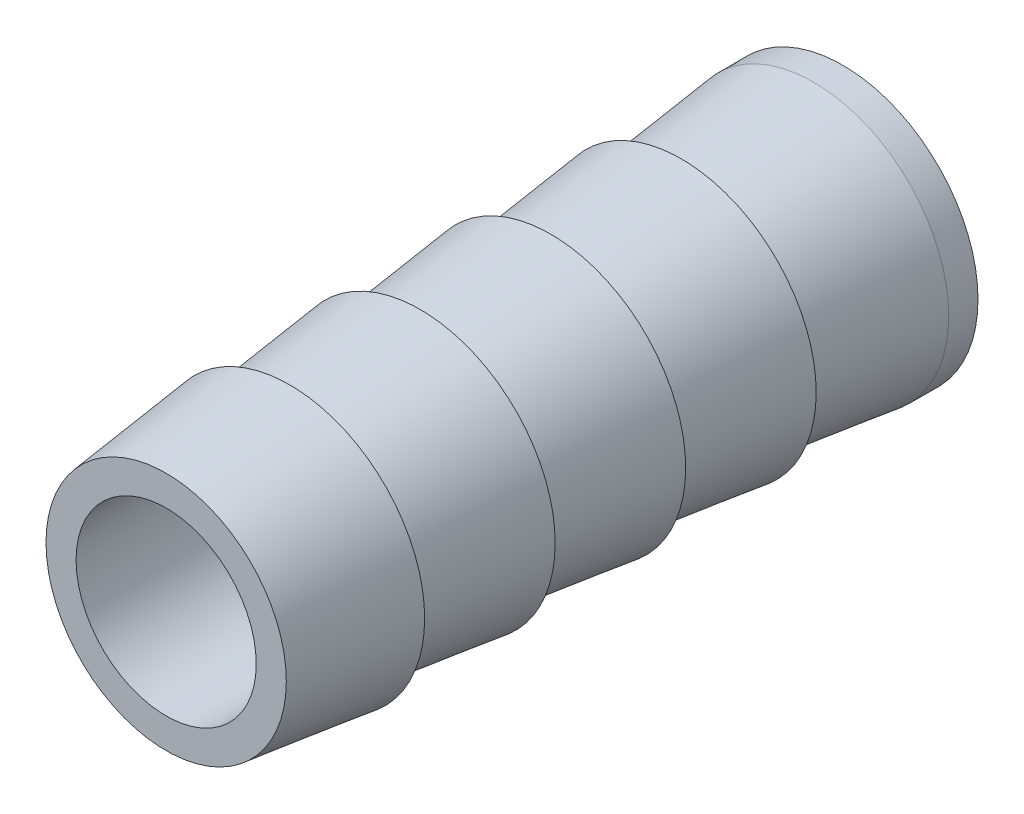
from build123d import *

# Parameters (mm, degrees)
SKETCH3_R          = 3.175
CUT_EXTRUDE1_DEPTH = 24.850898387


with BuildPart() as part:
    # Sketch2 → Barbfitting(Mcmaster) (revolve)
    with BuildSketch(Plane(origin=(0, 0, 0), x_dir=(0, 0, -1), z_dir=(1, 0, 0))):
        Polygon((-15.111710887, 0), (-15.111710887, 4.234813167), (-10.754464436, 4.753622494), (-10.754464436, 4.205934994), (-10.605348064, 4.223690006), (-6.154683186, 4.753622494), (-6.154683186, 4.205934994), (-6.005566814, 4.223690006), (-1.554901936, 4.753622494), (-1.554901936, 4.205934994), (-1.405785564, 4.223690006), (3.044879314, 4.753622494), (3.044879314, 4.205934994), (3.193995686, 4.223690006), (7.707996691, 4.76116381), (8.7391875, 4.7625), (8.7391875, 0), align=None)
    revolve(axis=Axis((0, 0, 15.2796875), (0, 0, -1)))

    # Sketch3 → Cut-Extrude1 (cut, through all)
    with BuildSketch(Plane.XY.offset(15.111710887)):
        Circle(SKETCH3_R)
    extrude(amount=-CUT_EXTRUDE1_DEPTH, mode=Mode.SUBTRACT)


solid = part.part
